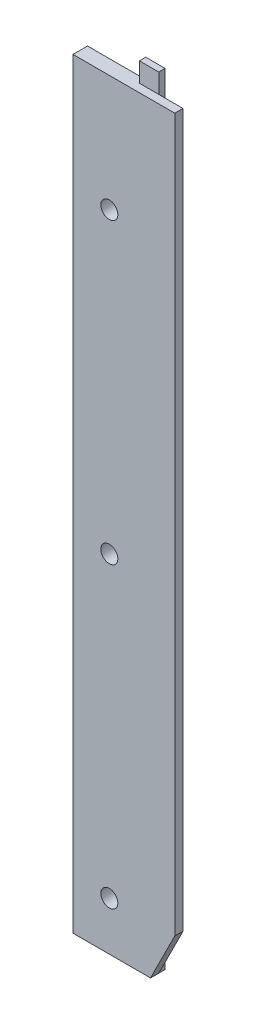
from build123d import *

# Parameters (mm, degrees)
SKETCH1_W               = 21
SKETCH1_H               = 157
BOSS_EXTRUDE1_DEPTH     = 1.7
BOSS_EXTRUDE2_DEPTH     = 1.3
SKETCH3_R               = 1.75
CUT_EXTRUDE1_DEPTH      = 4
CUT_EXTRUDE2_DEPTH      = 1
CUT_EXTRUDE2_DEPTH_BACK = 4


with BuildPart() as part:
    # Sketch1 → Boss-Extrude1 (new body)
    with BuildSketch(Plane.XY):
        Rectangle(SKETCH1_W, SKETCH1_H)
    extrude(amount=BOSS_EXTRUDE1_DEPTH)

    # Sketch2 → Boss-Extrude2 (add)
    with BuildSketch(Plane(origin=(0, 0, 0), x_dir=(-1, 0, 0), z_dir=(0, 0, -1))):
        Polygon((-5.5, 78.5), (-5.5, -78.5), (10.5, -78.5), (10.5, 78.5), (-1.5, 78.5), (-1.5, 82.5), (-5.5, 82.5), align=None)
    extrude(amount=BOSS_EXTRUDE2_DEPTH)

    # Sketch3 → Cut-Extrude1 (cut, through all)
    with BuildSketch(Plane.XY.offset(1.7)):
        with Locations((-3, 54.5)):
            Circle(SKETCH3_R)
        with Locations((-3, -7)):
            Circle(SKETCH3_R)
        with Locations((-3, -68.5)):
            Circle(SKETCH3_R)
    extrude(amount=-CUT_EXTRUDE1_DEPTH, mode=Mode.SUBTRACT)

    # Sketch4 → Cut-Extrude2 (cut, two sides)
    with BuildSketch(Plane.XY.offset(1.7)) as cut_extrude2_sk:
        Polygon((5.499288315, -78.5), (10.5, -68.500735895), (10.5, -78.5), align=None)
    extrude(amount=CUT_EXTRUDE2_DEPTH, mode=Mode.SUBTRACT)
    extrude(cut_extrude2_sk.sketch, amount=-CUT_EXTRUDE2_DEPTH_BACK, mode=Mode.SUBTRACT)


solid = part.part
